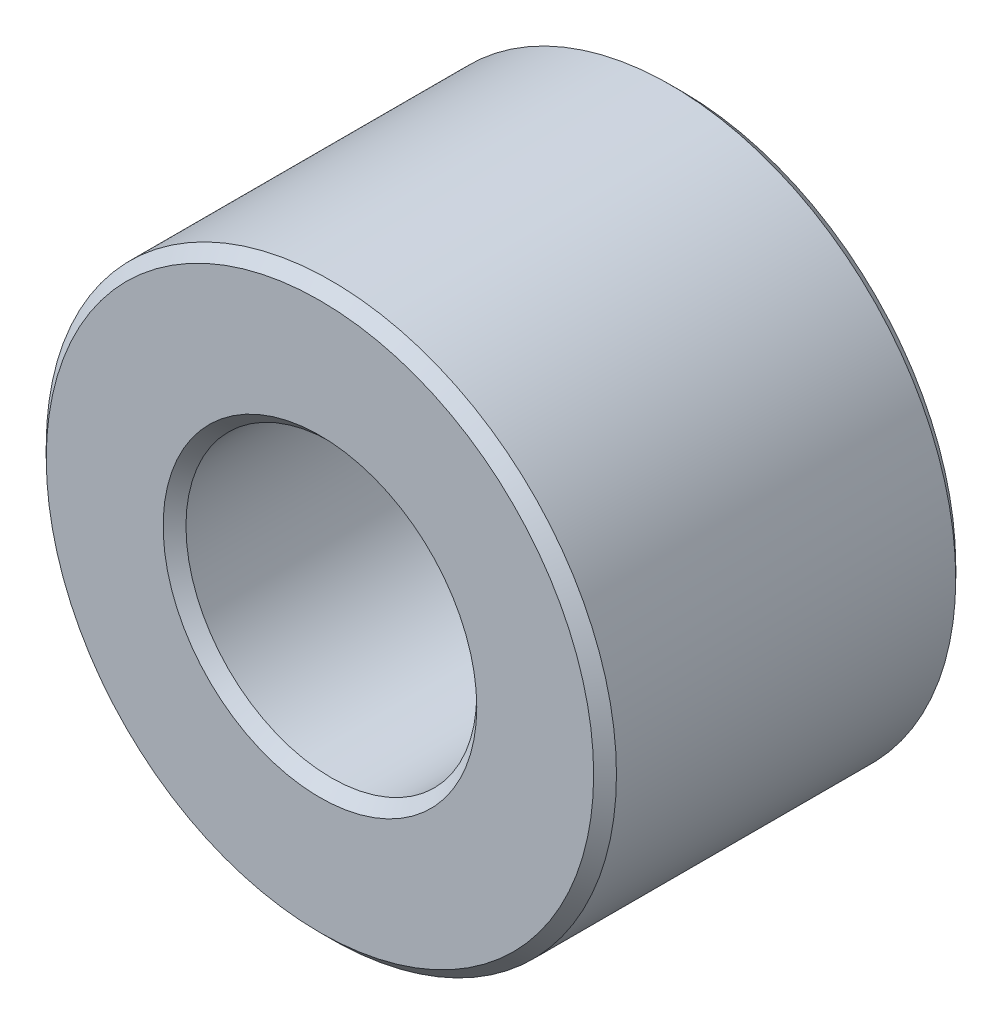
from build123d import *

# Parameters (mm, degrees)
SKETCH1_R           = 5
SKETCH1_R_2         = 2.55
BOSS_EXTRUDE1_DEPTH = 6.35
CHAMFER1_SIZE       = 0.2


with BuildPart() as part:
    # Sketch1 → Boss-Extrude1 (new body)
    with BuildSketch(Plane.XY):
        Circle(SKETCH1_R)
        Circle(SKETCH1_R_2, mode=Mode.SUBTRACT)
    extrude(amount=BOSS_EXTRUDE1_DEPTH)

    # Chamfer1
    chamfer1_edges = [part.edges().sort_by_distance(p)[0] for p in [
        (-5, 0, 0),
        (-5, 0, 6.35),
        (-2.55, 0, 0),
        (-2.55, 0, 6.35),
    ]]
    chamfer(chamfer1_edges, length=CHAMFER1_SIZE)


solid = part.part
